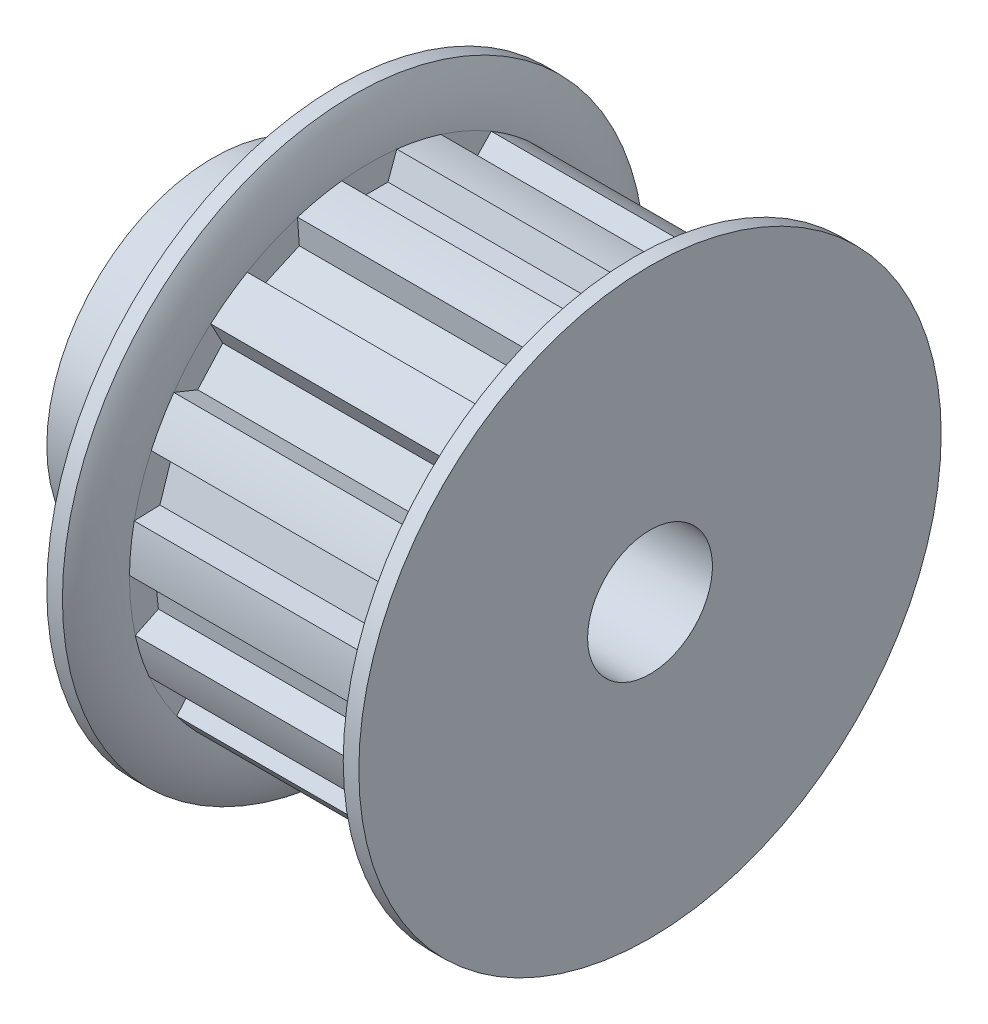
from build123d import *

# Parameters (mm, degrees)
CUT_EXTRUDE1_START = -3
CUT_EXTRUDE1_DEPTH = 12
CIRPATTERN1_COUNT  = 15


with BuildPart() as part:
    # Sketch1 → Revolve1 (revolve)
    with BuildSketch(Plane.XY, mode=Mode.PRIVATE) as revolve1_sk:
        with BuildLine():
            Line((-10.5, 3), (10.5, 3))
            Line((10.5, 3), (10.5, 14))
            Line((10.5, 14), (9.75, 14))
            ThreePointArc((9.75, 14), (9.191617437, 12.818070474), (9, 11.525))
            Line((9, 11.525), (-3, 11.525))
            ThreePointArc((-3, 11.525), (-3.191617437, 12.818070474), (-3.75, 14))
            Line((-3.75, 14), (-4.5, 14))
            Line((-4.5, 14), (-4.5, 8))
            Line((-4.5, 8), (-10.5, 8))
            Line((-10.5, 8), (-10.5, 3))
        make_face()
    revolve(revolve1_sk.sketch.rotate(Axis((-10.5, 0, 0), (1, 0, 0)), 90), axis=Axis((-10.5, 0, 0), (1, 0, 0)))

    # Sketch3 → Cut-Extrude1 (cut)
    with BuildSketch(Plane(origin=(0, 0, 0), x_dir=(0, 0, -1), z_dir=(1, 0, 0)).offset(CUT_EXTRUDE1_START)):
        with BuildLine():
            Line((-1.325, 11.448580698), (-0.901692109, 10.285551825))
            Line((-0.901692109, 10.285551825), (0.901692109, 10.285551825))
            Line((0.901692109, 10.285551825), (1.325, 11.448580698))
            ThreePointArc((1.325, 11.448580698), (0, 11.525), (-1.325, 11.448580698))
        make_face()
    cut_extrude1 = extrude(amount=CUT_EXTRUDE1_DEPTH, mode=Mode.SUBTRACT)

    # CirPattern1: Cut-Extrude1 ×15 about axis
    cirpattern1_axis = Axis((0, 0, 0), (1, 0, 0))
    for i in range(1, CIRPATTERN1_COUNT):
        add(cut_extrude1.rotate(cirpattern1_axis, i * 360 / CIRPATTERN1_COUNT), mode=Mode.SUBTRACT)


solid = part.part
